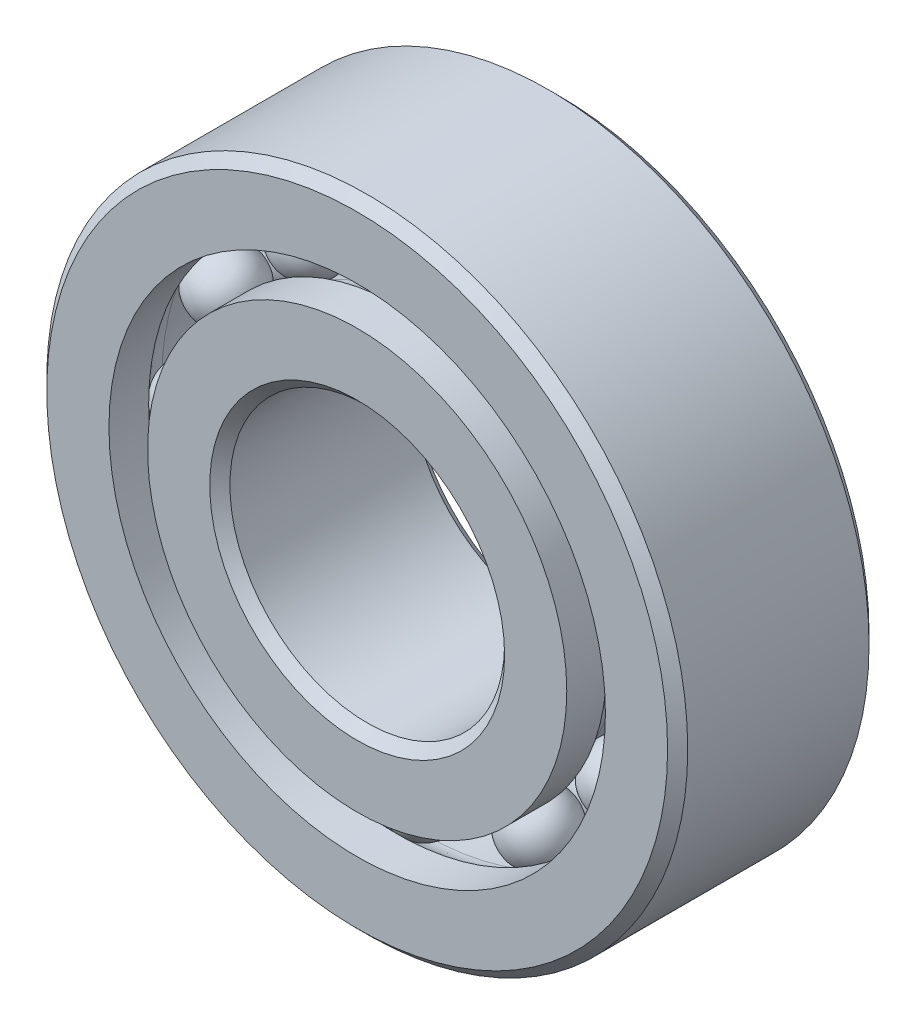
from build123d import *

# Parameters (mm, degrees)
CIRPATTERN1_COUNT = 12


with BuildPart() as part:
    # Sketch1 → Revolve1 (revolve)
    with BuildSketch(Plane(origin=(0, 0, 0), x_dir=(0, 0, -1), z_dir=(1, 0, 0))):
        with BuildLine():
            Line((4.95, 17.5), (-4.95, 17.5))
            Line((-4.95, 17.5), (-5.5, 16.95))
            Line((-5.5, 16.95), (-5.5, 13.554945055))
            Line((-5.5, 13.554945055), (-3.332733894, 13.554945055))
            ThreePointArc((-3.332733894, 13.554945055), (-2.678035996, 14.127141212), (-1.833333333, 14.333333333))
            Line((-1.833333333, 14.333333333), (1.833333333, 14.333333333))
            ThreePointArc((1.833333333, 14.333333333), (2.678035996, 14.127141212), (3.332733894, 13.554945055))
            Line((3.332733894, 13.554945055), (5.5, 13.554945055))
            Line((5.5, 13.554945055), (5.5, 16.95))
            Line((5.5, 16.95), (4.95, 17.5))
        make_face()
    revolve(axis=Axis((0, 0, 5.5), (0, 0, -1)))


with BuildPart() as body_2:
    # Sketch3 → Revolve3 (revolve)
    with BuildSketch(Plane(origin=(0, 0, 0), x_dir=(0, 0, -1), z_dir=(1, 0, 0))):
        with BuildLine():
            Line((-5.5, 11.445054945), (-3.332733894, 11.445054945))
            ThreePointArc((-3.332733894, 11.445054945), (-2.678035996, 10.872858788), (-1.833333333, 10.666666667))
            Line((-1.833333333, 10.666666667), (1.833333333, 10.666666667))
            ThreePointArc((1.833333333, 10.666666667), (2.678035996, 10.872858788), (3.332733894, 11.445054945))
            Line((3.332733894, 11.445054945), (5.5, 11.445054945))
            Line((5.5, 11.445054945), (5.5, 8.05))
            Line((5.5, 8.05), (4.95, 7.5))
            Line((4.95, 7.5), (-4.95, 7.5))
            Line((-4.95, 7.5), (-5.5, 8.05))
            Line((-5.5, 8.05), (-5.5, 11.445054945))
        make_face()
    revolve(axis=Axis((0, 0, 5.5), (0, 0, -1)))


with BuildPart() as body_3:
    # Sketch4 → Revolve4 (revolve)
    with BuildSketch(Plane(origin=(0, 0, 0), x_dir=(0, 0, -1), z_dir=(1, 0, 0))):
        with BuildLine():
            Line((0, 12.5), (3.666666667, 12.5))
            ThreePointArc((3.666666667, 12.5), (1.833333333, 14.333333333), (0, 12.5))
        make_face()
    revolve(axis=Axis((0, 12.5, 0), (0, 0, -1)))


with BuildPart() as body_4:
    # Mirror1: mirrored copy
    add(body_3.part.mirror(Plane.XY))


with BuildPart() as cirpattern1_1:
    # CirPattern1: pattern copy
    add(body_3.part.rotate(Axis((0, 0, -5.5), (0, 0, 1)), 1 * 360 / CIRPATTERN1_COUNT))


with BuildPart() as cirpattern1_2:
    # CirPattern1: pattern copy
    add(body_3.part.rotate(Axis((0, 0, -5.5), (0, 0, 1)), 2 * 360 / CIRPATTERN1_COUNT))


with BuildPart() as cirpattern1_3:
    # CirPattern1: pattern copy
    add(body_3.part.rotate(Axis((0, 0, -5.5), (0, 0, 1)), 3 * 360 / CIRPATTERN1_COUNT))


with BuildPart() as cirpattern1_4:
    # CirPattern1: pattern copy
    add(body_3.part.rotate(Axis((0, 0, -5.5), (0, 0, 1)), 4 * 360 / CIRPATTERN1_COUNT))


with BuildPart() as cirpattern1_5:
    # CirPattern1: pattern copy
    add(body_3.part.rotate(Axis((0, 0, -5.5), (0, 0, 1)), 5 * 360 / CIRPATTERN1_COUNT))


with BuildPart() as cirpattern1_6:
    # CirPattern1: pattern copy
    add(body_3.part.rotate(Axis((0, 0, -5.5), (0, 0, 1)), 6 * 360 / CIRPATTERN1_COUNT))


with BuildPart() as cirpattern1_7:
    # CirPattern1: pattern copy
    add(body_3.part.rotate(Axis((0, 0, -5.5), (0, 0, 1)), 7 * 360 / CIRPATTERN1_COUNT))


with BuildPart() as cirpattern1_8:
    # CirPattern1: pattern copy
    add(body_3.part.rotate(Axis((0, 0, -5.5), (0, 0, 1)), 8 * 360 / CIRPATTERN1_COUNT))


with BuildPart() as cirpattern1_9:
    # CirPattern1: pattern copy
    add(body_3.part.rotate(Axis((0, 0, -5.5), (0, 0, 1)), 9 * 360 / CIRPATTERN1_COUNT))


with BuildPart() as cirpattern1_10:
    # CirPattern1: pattern copy
    add(body_3.part.rotate(Axis((0, 0, -5.5), (0, 0, 1)), 10 * 360 / CIRPATTERN1_COUNT))


with BuildPart() as cirpattern1_11:
    # CirPattern1: pattern copy
    add(body_3.part.rotate(Axis((0, 0, -5.5), (0, 0, 1)), 11 * 360 / CIRPATTERN1_COUNT))


with BuildPart() as cirpattern1_12:
    # CirPattern1: pattern copy
    add(body_4.part.rotate(Axis((0, 0, -5.5), (0, 0, 1)), 1 * 360 / CIRPATTERN1_COUNT))


with BuildPart() as cirpattern1_13:
    # CirPattern1: pattern copy
    add(body_4.part.rotate(Axis((0, 0, -5.5), (0, 0, 1)), 2 * 360 / CIRPATTERN1_COUNT))


with BuildPart() as cirpattern1_14:
    # CirPattern1: pattern copy
    add(body_4.part.rotate(Axis((0, 0, -5.5), (0, 0, 1)), 3 * 360 / CIRPATTERN1_COUNT))


with BuildPart() as cirpattern1_15:
    # CirPattern1: pattern copy
    add(body_4.part.rotate(Axis((0, 0, -5.5), (0, 0, 1)), 4 * 360 / CIRPATTERN1_COUNT))


with BuildPart() as cirpattern1_16:
    # CirPattern1: pattern copy
    add(body_4.part.rotate(Axis((0, 0, -5.5), (0, 0, 1)), 5 * 360 / CIRPATTERN1_COUNT))


with BuildPart() as cirpattern1_17:
    # CirPattern1: pattern copy
    add(body_4.part.rotate(Axis((0, 0, -5.5), (0, 0, 1)), 6 * 360 / CIRPATTERN1_COUNT))


with BuildPart() as cirpattern1_18:
    # CirPattern1: pattern copy
    add(body_4.part.rotate(Axis((0, 0, -5.5), (0, 0, 1)), 7 * 360 / CIRPATTERN1_COUNT))


with BuildPart() as cirpattern1_19:
    # CirPattern1: pattern copy
    add(body_4.part.rotate(Axis((0, 0, -5.5), (0, 0, 1)), 8 * 360 / CIRPATTERN1_COUNT))


with BuildPart() as cirpattern1_20:
    # CirPattern1: pattern copy
    add(body_4.part.rotate(Axis((0, 0, -5.5), (0, 0, 1)), 9 * 360 / CIRPATTERN1_COUNT))


with BuildPart() as cirpattern1_21:
    # CirPattern1: pattern copy
    add(body_4.part.rotate(Axis((0, 0, -5.5), (0, 0, 1)), 10 * 360 / CIRPATTERN1_COUNT))


with BuildPart() as cirpattern1_22:
    # CirPattern1: pattern copy
    add(body_4.part.rotate(Axis((0, 0, -5.5), (0, 0, 1)), 11 * 360 / CIRPATTERN1_COUNT))


solid = Compound([part.part, body_2.part, body_3.part, body_4.part, cirpattern1_1.part, cirpattern1_2.part, cirpattern1_3.part, cirpattern1_4.part, cirpattern1_5.part, cirpattern1_6.part, cirpattern1_7.part, cirpattern1_8.part, cirpattern1_9.part, cirpattern1_10.part, cirpattern1_11.part, cirpattern1_12.part, cirpattern1_13.part, cirpattern1_14.part, cirpattern1_15.part, cirpattern1_16.part, cirpattern1_17.part, cirpattern1_18.part, cirpattern1_19.part, cirpattern1_20.part, cirpattern1_21.part, cirpattern1_22.part])
